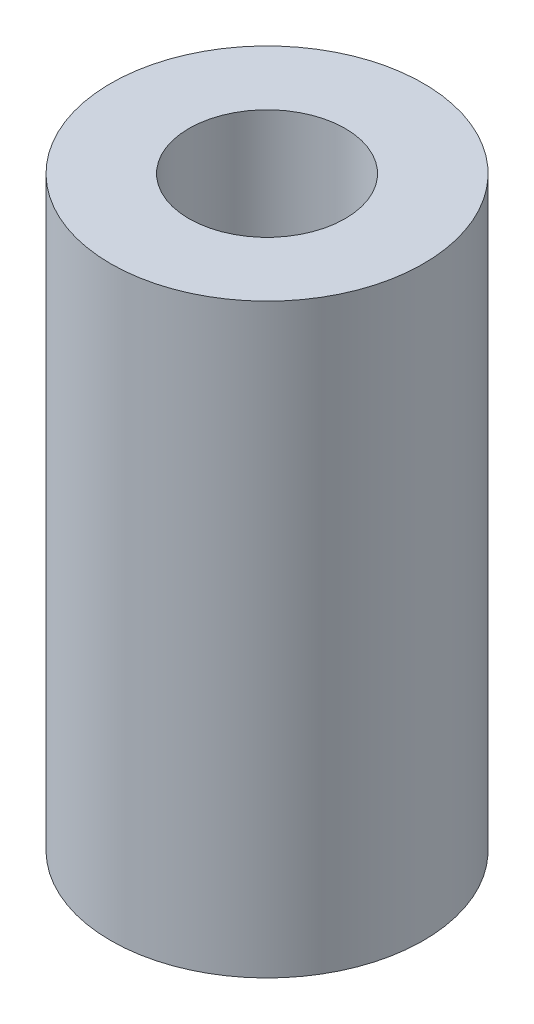
from build123d import *

# Parameters (mm, degrees)
SKETCH1_R           = 8
SKETCH1_R_2         = 4
BOSS_EXTRUDE1_DEPTH = 30


with BuildPart() as part:
    # Sketch1 → Boss-Extrude1 (new body)
    with BuildSketch(Plane(origin=(0, 0, 0), x_dir=(1, 0, 0), z_dir=(0, 1, 0))):
        Circle(SKETCH1_R)
        Circle(SKETCH1_R_2, mode=Mode.SUBTRACT)
    extrude(amount=BOSS_EXTRUDE1_DEPTH)


solid = part.part
